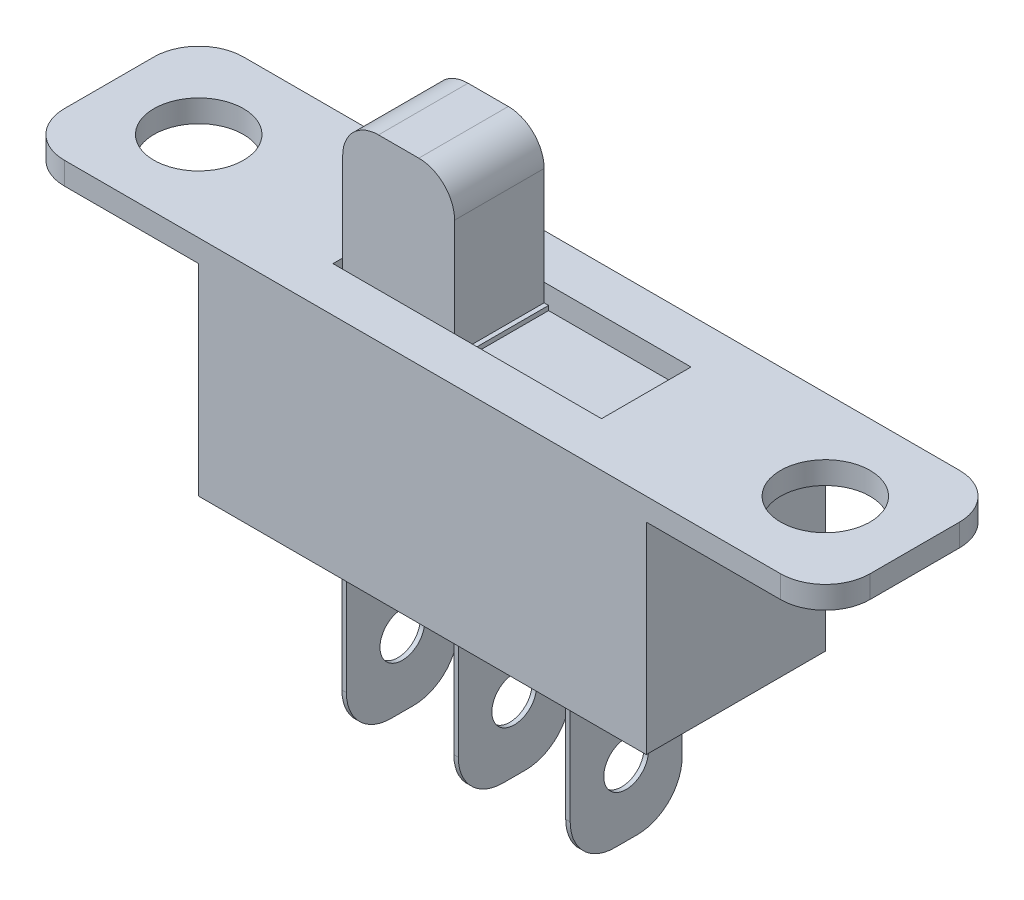
from build123d import *

# Parameters (mm, degrees)
SKETCH2_W                  = 10
SKETCH2_H                  = 4
BOSS_EXTRUDE1_DEPTH        = 5
SKETCH3_W                  = 6
SKETCH3_H                  = 2
CUT_EXTRUDE1_DEPTH         = 0.5
SKETCH4_W                  = 4
SKETCH4_H                  = 0.5
BOSS_EXTRUDE2_DEPTH        = 4
SKETCH5_R                  = 1
CUT_EXTRUDE2_DEPTH         = 1.5
FILLET1_R                  = 1
SKETCH6_W                  = 2.5
SKETCH6_H                  = 2
BOSS_EXTRUDE3_DEPTH        = 3.5
FILLET2_R                  = 0.8
SKETCH7_W                  = 0.1
SKETCH7_H                  = 2
BOSS_EXTRUDE4_DEPTH        = 0.1
SKETCH8_W                  = 9.7
SKETCH8_H                  = 3.7
CUT_EXTRUDE3_DEPTH         = 0.1
SKETCH9_W                  = 0.1
SKETCH9_H                  = 2.5
BOSS_EXTRUDE5_DEPTH        = 4
FILLET3_R                  = 1
SKETCH10_R                 = 0.5
CUT_EXTRUDE4_DEPTH         = 10.05
LPATTERN1_COUNT            = 2
LPATTERN1_PITCH            = 2.5
FILLET3_OF_LPATTERN1_R     = 1
LPATTERN1_COL_COUNT        = 2
LPATTERN1_COL_PITCH        = 2.5
FILLET3_OF_LPATTERN1_COL_R = 1


with BuildPart() as part:
    # Sketch2 → Boss-Extrude1 (new body)
    with BuildSketch(Plane(origin=(0, 0, 0), x_dir=(1, 0, 0), z_dir=(0, 1, 0))):
        Rectangle(SKETCH2_W, SKETCH2_H)
    extrude(amount=BOSS_EXTRUDE1_DEPTH)

    # Sketch3 → Cut-Extrude1 (cut)
    with BuildSketch(Plane(origin=(0, 5, 0), x_dir=(1, 0, 0), z_dir=(0, 1, 0))):
        Rectangle(SKETCH3_W, SKETCH3_H)
    extrude(amount=-CUT_EXTRUDE1_DEPTH, mode=Mode.SUBTRACT)

    # Sketch4 → Boss-Extrude2 (add)
    with BuildSketch(Plane(origin=(5, 0, 0), x_dir=(0, 0, -1), z_dir=(1, 0, 0))):
        with Locations((0, 4.75)):
            Rectangle(SKETCH4_W, SKETCH4_H)
    boss_extrude2 = extrude(amount=BOSS_EXTRUDE2_DEPTH)

    # Sketch5 → Cut-Extrude2 (cut, through all)
    with BuildSketch(Plane.XZ.offset(-4.5)):
        with Locations((7, 0)):
            Circle(SKETCH5_R)
    cut_extrude2 = extrude(amount=-CUT_EXTRUDE2_DEPTH, mode=Mode.SUBTRACT)

    # Mirror3: Boss-Extrude2, Cut-Extrude2 across plane
    add(boss_extrude2.mirror(Plane(origin=(0, 0, 0), x_dir=(0, 0, 1), z_dir=(1, 0, 0))))
    add(cut_extrude2.mirror(Plane(origin=(0, 0, 0), x_dir=(0, 0, 1), z_dir=(1, 0, 0))), mode=Mode.SUBTRACT)

    # Fillet1
    fillet1_edges = [part.edges().sort_by_distance(p)[0] for p in [
        (9, 4.75, 2),
        (9, 4.75, -2),
        (-9, 4.75, 2),
        (-9, 4.75, -2),
    ]]
    fillet(fillet1_edges, radius=FILLET1_R)

    # Sketch6 → Boss-Extrude3 (add)
    with BuildSketch(Plane(origin=(0, 4.5, 0), x_dir=(1, 0, 0), z_dir=(0, 1, 0))):
        with Locations((-1.53254506, 0)):
            Rectangle(SKETCH6_W, SKETCH6_H)
    extrude(amount=BOSS_EXTRUDE3_DEPTH)

    # Fillet2
    fillet2_edges = [part.edges().sort_by_distance(p)[0] for p in [
        (-2.78254506, 8, 0),
        (-0.28254506, 8, 0),
    ]]
    fillet(fillet2_edges, radius=FILLET2_R)

    # Sketch7 → Boss-Extrude4 (add)
    with BuildSketch(Plane(origin=(0, 4.5, 0), x_dir=(1, 0, 0), z_dir=(0, 1, 0))):
        with Locations((-0.23254506, 0)):
            Rectangle(SKETCH7_W, SKETCH7_H)
        with Locations((-2.83254506, 0)):
            Rectangle(SKETCH7_W, SKETCH7_H)
    extrude(amount=BOSS_EXTRUDE4_DEPTH)

    # Sketch8 → Cut-Extrude3 (cut)
    with BuildSketch(Plane.XZ):
        Rectangle(SKETCH8_W, SKETCH8_H)
    extrude(amount=-CUT_EXTRUDE3_DEPTH, mode=Mode.SUBTRACT)

    # Sketch9 → Boss-Extrude5 (add)
    with BuildSketch(Plane.XZ.offset(-0.1)):
        Rectangle(SKETCH9_W, SKETCH9_H)
    boss_extrude5 = extrude(amount=BOSS_EXTRUDE5_DEPTH)

    # Fillet3
    fillet3_edges = [part.edges().sort_by_distance(p)[0] for p in [
        (0, -3.9, 1.25),
        (0, -3.9, -1.25),
    ]]
    fillet(fillet3_edges, radius=FILLET3_R)

    # Sketch10 → Cut-Extrude4 (cut, through all)
    with BuildSketch(Plane.ZY.offset(0.05)):
        with Locations((0, -2.4)):
            Circle(SKETCH10_R)
    cut_extrude4 = extrude(amount=-CUT_EXTRUDE4_DEPTH, mode=Mode.SUBTRACT)

    # LPattern1: Boss-Extrude5, Cut-Extrude4 ×2
    with Locations(*[(i * LPATTERN1_PITCH, 0, 0) for i in range(1, LPATTERN1_COUNT)]):
        add(boss_extrude5)
        add(cut_extrude4, mode=Mode.SUBTRACT)

    # Fillet3 of LPattern1
    fillet3_of_lpattern1_edges = [part.edges().sort_by_distance(p)[0] for p in [
        (2.5, -3.9, 1.25),
        (2.5, -3.9, -1.25),
    ]]
    fillet(fillet3_of_lpattern1_edges, radius=FILLET3_OF_LPATTERN1_R)

    # LPattern1 col: Boss-Extrude5, Cut-Extrude4 ×2
    with Locations(*[(-i * LPATTERN1_COL_PITCH, 0, 0) for i in range(1, LPATTERN1_COL_COUNT)]):
        add(boss_extrude5)
        add(cut_extrude4, mode=Mode.SUBTRACT)

    # Fillet3 of LPattern1 col
    fillet3_of_lpattern1_col_edges = [part.edges().sort_by_distance(p)[0] for p in [
        (-2.5, -3.9, 1.25),
        (-2.5, -3.9, -1.25),
    ]]
    fillet(fillet3_of_lpattern1_col_edges, radius=FILLET3_OF_LPATTERN1_COL_R)


solid = part.part
